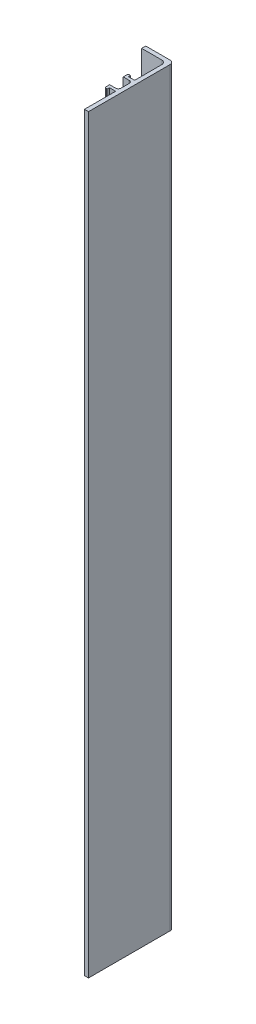
from build123d import *

# Parameters (mm, degrees)
SALIENTE_EXTRUIR1_DEPTH = 276.5
REDONDEO1_R             = 0.5
REDONDEO2_R             = 1
REDONDEO3_R             = 1.5
REDONDEO4_R             = 1.5


with BuildPart() as part:
    # Croquis1 → Saliente-Extruir1 (new body)
    with BuildSketch(Plane(origin=(0, 0, 0), x_dir=(1, 0, 0), z_dir=(0, 1, 0))):
        Polygon((0, 0), (0, 31.5), (-10.4, 31.5), (-10.4, 30), (-1.5, 30), (-1.5, 18.5), (-3.8, 18.5), (-3.8, 19.3), (-4.7, 19.3), (-4.7, 17.5), (-1.5, 17.5), (-1.5, 12.5), (-4.7, 12.5), (-4.7, 10.7), (-3.8, 10.7), (-3.8, 11.5), (-1.5, 11.5), (-1.5, 0), align=None)
    extrude(amount=SALIENTE_EXTRUIR1_DEPTH)

    # Redondeo1
    redondeo1_edges = [part.edges().sort_by_distance(p)[0] for p in [
        (-4.7, 138.25, -10.7),
        (-4.7, 138.25, -19.3),
    ]]
    fillet(redondeo1_edges, radius=REDONDEO1_R)

    # Redondeo2
    redondeo2_edges = [part.edges().sort_by_distance(p)[0] for p in [
        (-1.5, 138.25, -12.5),
        (-1.5, 138.25, -17.5),
    ]]
    fillet(redondeo2_edges, radius=REDONDEO2_R)

    # Redondeo3
    redondeo3_edges = [part.edges().sort_by_distance(p)[0] for p in [
        (-1.5, 138.25, -30),
    ]]
    fillet(redondeo3_edges, radius=REDONDEO3_R)

    # Redondeo4
    redondeo4_edges = [part.edges().sort_by_distance(p)[0] for p in [
        (0, 138.25, -31.5),
    ]]
    fillet(redondeo4_edges, radius=REDONDEO4_R)


solid = part.part
